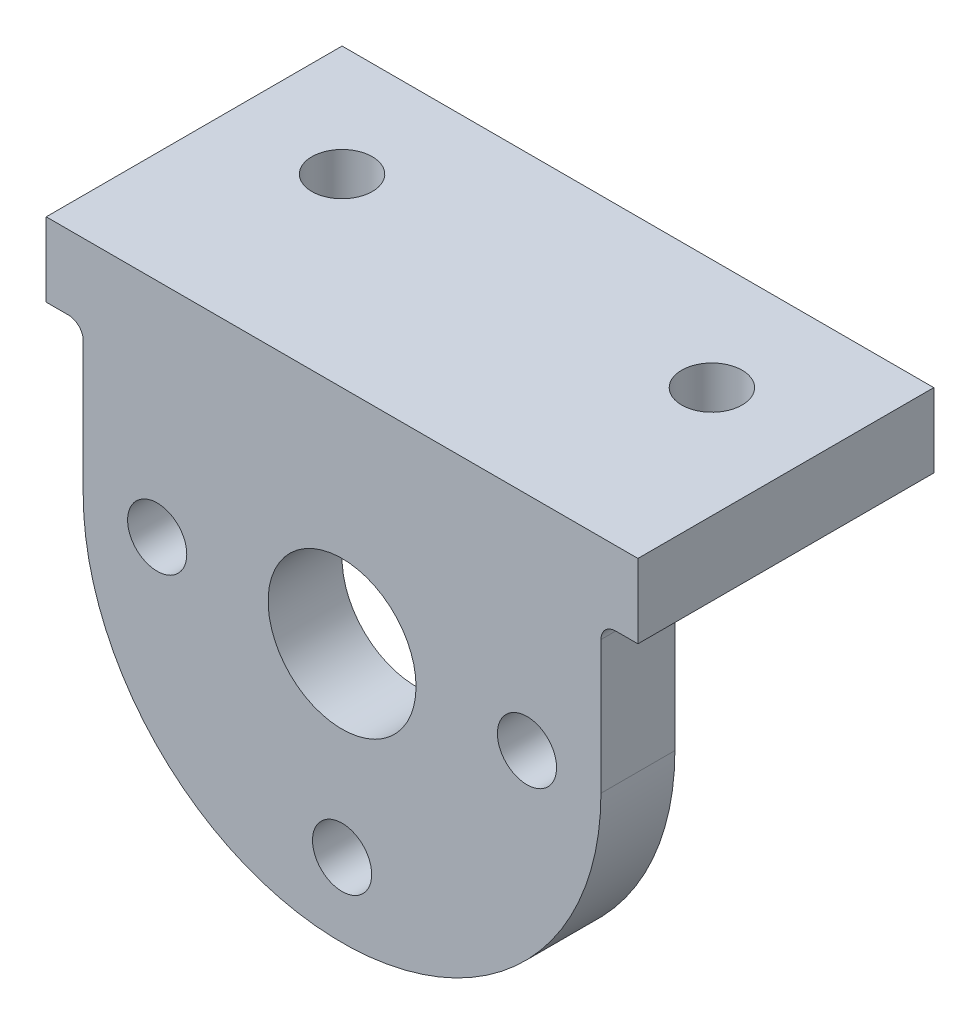
from build123d import *

# Parameters (mm, degrees)
BOSS_EXTRUDE1_DEPTH = 12.7
BOSS_EXTRUDE2_DEPTH = 38.1
SKETCH4_R           = 12.7
SKETCH4_R_2         = 5.08
CUT_EXTRUDE1_DEPTH  = 110.433918417
SKETCH3_R           = 5.18795
CUT_EXTRUDE2_DEPTH  = 95.399536545
FILLET1_R           = 2.54


with BuildPart() as part:
    # Sketch1 → Boss-Extrude1 (new body)
    with BuildSketch(Plane.XY):
        with BuildLine():
            Line((50.8, -12.7), (50.8, 0))
            Line((50.8, 0), (-50.8, 0))
            Line((-50.8, 0), (-50.8, -12.7))
            Line((-50.8, -12.7), (-44.45, -12.7))
            Line((-44.45, -12.7), (-44.45, -38.1))
            ThreePointArc((-44.45, -38.1), (0, -82.55), (44.45, -38.1))
            Line((44.45, -38.1), (44.45, -12.7))
            Line((44.45, -12.7), (50.8, -12.7))
        make_face()
    extrude(amount=BOSS_EXTRUDE1_DEPTH)

    # Sketch1_4 → Boss-Extrude2 (add)
    with BuildSketch(Plane.XY):
        Polygon((50.8, -12.7), (50.8, 0), (-50.8, 0), (-50.8, -12.7), (-44.45, -12.7), (44.45, -12.7), align=None)
    extrude(amount=-BOSS_EXTRUDE2_DEPTH)

    # Sketch4 → Cut-Extrude1 (cut, through all)
    with BuildSketch(Plane.XY.offset(12.7)):
        with Locations((0, -38.1)):
            Circle(SKETCH4_R)
        with Locations((-31.75, -38.1)):
            Circle(SKETCH4_R_2)
        with Locations((31.75, -38.1)):
            Circle(SKETCH4_R_2)
        with Locations((0, -69.85)):
            Circle(SKETCH4_R_2)
    extrude(amount=-CUT_EXTRUDE1_DEPTH, mode=Mode.SUBTRACT)

    # Sketch3 → Cut-Extrude2 (cut, through all)
    with BuildSketch(Plane.XZ.offset(12.7)):
        with Locations((-31.75, -19.05)):
            Circle(SKETCH3_R)
        with Locations((31.75, -19.05)):
            Circle(SKETCH3_R)
    extrude(amount=-CUT_EXTRUDE2_DEPTH, mode=Mode.SUBTRACT)

    # Fillet1
    fillet1_edges = [part.edges().sort_by_distance(p)[0] for p in [
        (0, -12.7, 0),
        (44.45, -12.7, 6.35),
        (-44.45, -12.7, 6.35),
    ]]
    fillet(fillet1_edges, radius=FILLET1_R)


solid = part.part
